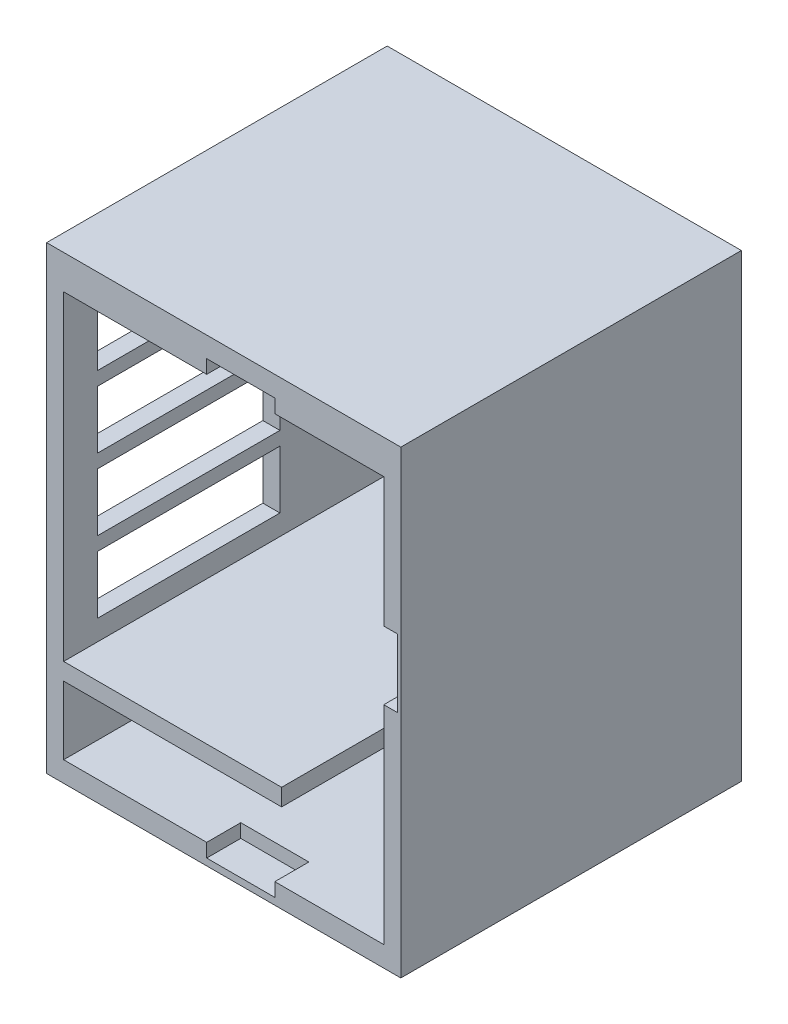
from build123d import *

# Parameters (mm, degrees)
SKETCH_1_W          = 104
SKETCH_1_H          = 135
SKETCH_1_R          = 47
EXTRUDE_2_DEPTH     = 100
SKETCH_2_W          = 94
SKETCH_2_H          = 94
CUT_EXTRUDE_1_DEPTH = 95
SKETCH_3_W          = 30
SKETCH_3_H          = 5
SKETCH_3_W_2        = 94
SKETCH_3_H_2        = 20
CUT_EXTRUDE_3_DEPTH = 70
SKETCH_4_W          = 20
SKETCH_4_H          = 4
SKETCH_4_W_2        = 4
SKETCH_4_H_2        = 20
CUT_EXTRUDE_4_DEPTH = 10
CUT_EXTRUDE_6_REACH = 106
SKETCH_6_W          = 53.5
SKETCH_6_H          = 17
CUT_EXTRUDE_7_REACH = 137
SKETCH_7_W          = 12
SKETCH_7_H          = 12


with BuildPart() as part:
    # 草圖1 → 填料-伸長2 (new body)
    with BuildSketch(Plane.XY):
        with Locations((-20.894077044, -18.213740458)):
            Rectangle(SKETCH_1_W, SKETCH_1_H)
        with Locations((-20.894077044, -7.713740458)):
            Circle(SKETCH_1_R, mode=Mode.SUBTRACT)
    extrude(amount=EXTRUDE_2_DEPTH)

    # 草圖2 → 除料-伸長1 (cut)
    with BuildSketch(Plane.XY.offset(100)):
        with Locations((-20.894077044, -7.713740458)):
            Rectangle(SKETCH_2_W, SKETCH_2_H)
    extrude(amount=-CUT_EXTRUDE_1_DEPTH, mode=Mode.SUBTRACT)

    # 草圖3 → 除料-伸長3 (cut)
    with BuildSketch(Plane.XY.offset(100)):
        with Locations((11.105922956, -57.213740458)):
            Rectangle(SKETCH_3_W, SKETCH_3_H)
        with Locations((-20.894077044, -69.713740458)):
            Rectangle(SKETCH_3_W_2, SKETCH_3_H_2)
    extrude(amount=-CUT_EXTRUDE_3_DEPTH, mode=Mode.SUBTRACT)

    # 草圖4 → 除料-伸長4 (cut)
    with BuildSketch(Plane.XY.offset(100)):
        with Locations((-15.894077044, -81.713740458)):
            Rectangle(SKETCH_4_W, SKETCH_4_H)
        with Locations((28.105922956, -8.713740458)):
            Rectangle(SKETCH_4_W_2, SKETCH_4_H_2)
        with Locations((-15.894077044, 41.286259542)):
            Rectangle(SKETCH_4_W, SKETCH_4_H)
    extrude(amount=-CUT_EXTRUDE_4_DEPTH, mode=Mode.SUBTRACT)

    # 草圖6 → 除料-伸長6 (cut, up to next)
    with BuildSketch(Plane.ZY.offset(72.894077044), mode=Mode.PRIVATE) as cut_extrude_6_sk1:
        with Locations((63.25, 22.786259542)):
            Rectangle(SKETCH_6_W, SKETCH_6_H)
    cut_extrude_6_tool1 = extrude(cut_extrude_6_sk1.sketch, amount=-CUT_EXTRUDE_6_REACH, mode=Mode.PRIVATE) & part.part
    add(cut_extrude_6_tool1.solids().sort_by_distance((-72.894077, 22.78626, 63.25))[0], mode=Mode.SUBTRACT)
    # 草圖6 → 除料-伸長6 (cut, up to next)
    with BuildSketch(Plane.ZY.offset(72.894077044), mode=Mode.PRIVATE) as cut_extrude_6_sk2:
        with Locations((63.25, 1.786259542)):
            Rectangle(SKETCH_6_W, SKETCH_6_H)
    cut_extrude_6_tool2 = extrude(cut_extrude_6_sk2.sketch, amount=-CUT_EXTRUDE_6_REACH, mode=Mode.PRIVATE) & part.part
    add(cut_extrude_6_tool2.solids().sort_by_distance((-72.894077, 1.78626, 63.25))[0], mode=Mode.SUBTRACT)
    # 草圖6 → 除料-伸長6 (cut, up to next)
    with BuildSketch(Plane.ZY.offset(72.894077044), mode=Mode.PRIVATE) as cut_extrude_6_sk3:
        with Locations((63.25, -19.213740458)):
            Rectangle(SKETCH_6_W, SKETCH_6_H)
    cut_extrude_6_tool3 = extrude(cut_extrude_6_sk3.sketch, amount=-CUT_EXTRUDE_6_REACH, mode=Mode.PRIVATE) & part.part
    add(cut_extrude_6_tool3.solids().sort_by_distance((-72.894077, -19.21374, 63.25))[0], mode=Mode.SUBTRACT)
    # 草圖6 → 除料-伸長6 (cut, up to next)
    with BuildSketch(Plane.ZY.offset(72.894077044), mode=Mode.PRIVATE) as cut_extrude_6_sk4:
        with Locations((63.25, -40.213740458)):
            Rectangle(SKETCH_6_W, SKETCH_6_H)
    cut_extrude_6_tool4 = extrude(cut_extrude_6_sk4.sketch, amount=-CUT_EXTRUDE_6_REACH, mode=Mode.PRIVATE) & part.part
    add(cut_extrude_6_tool4.solids().sort_by_distance((-72.894077, -40.21374, 63.25))[0], mode=Mode.SUBTRACT)

    # 草圖7 → 除料-伸長7 (cut, up to next)
    with BuildSketch(Plane.XZ.offset(85.713740458), mode=Mode.PRIVATE) as cut_extrude_7_sk1:
        with Locations((5.105922956, 49)):
            Rectangle(SKETCH_7_W, SKETCH_7_H)
    cut_extrude_7_tool1 = extrude(cut_extrude_7_sk1.sketch, amount=-CUT_EXTRUDE_7_REACH, mode=Mode.PRIVATE) & part.part
    add(cut_extrude_7_tool1.solids().sort_by_distance((5.105923, -85.71374, 49))[0], mode=Mode.SUBTRACT)
    # 草圖7 → 除料-伸長7 (cut, up to next)
    with BuildSketch(Plane.XZ.offset(85.713740458), mode=Mode.PRIVATE) as cut_extrude_7_sk2:
        with Locations((-46.894077044, 49)):
            Rectangle(SKETCH_7_W, SKETCH_7_H)
    cut_extrude_7_tool2 = extrude(cut_extrude_7_sk2.sketch, amount=-CUT_EXTRUDE_7_REACH, mode=Mode.PRIVATE) & part.part
    add(cut_extrude_7_tool2.solids().sort_by_distance((-46.894077, -85.71374, 49))[0], mode=Mode.SUBTRACT)


solid = part.part
